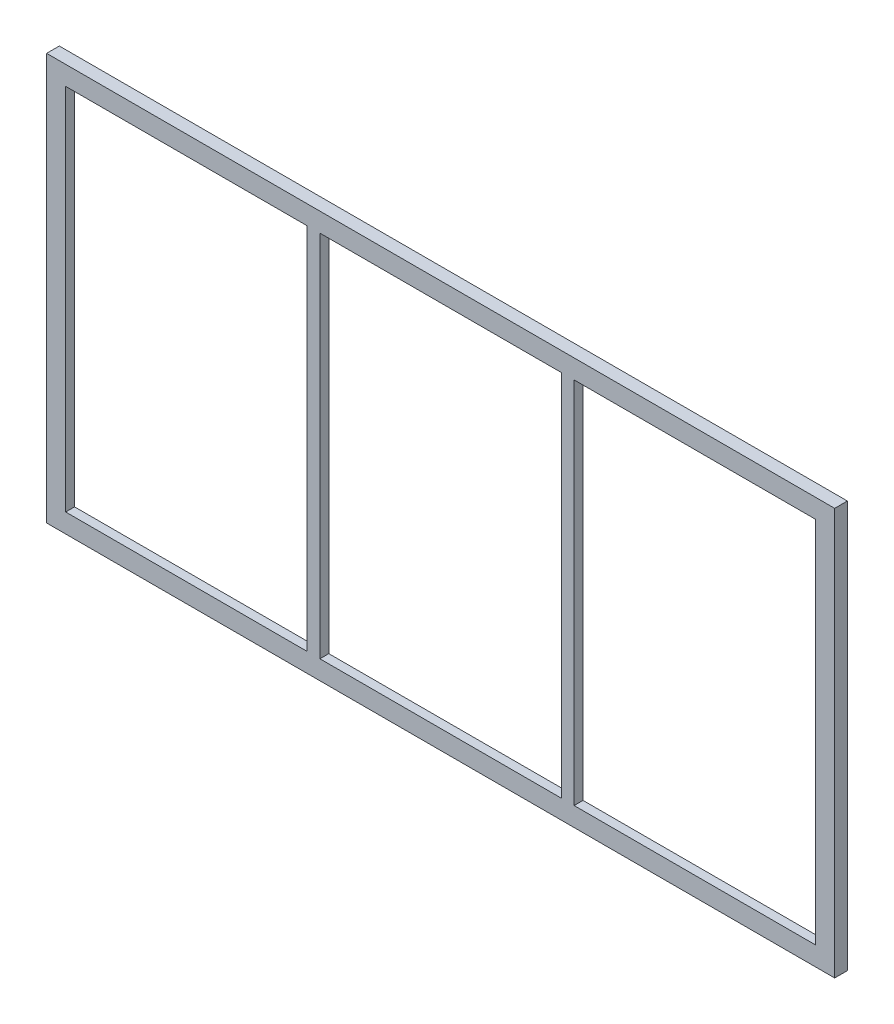
from build123d import *

# Parameters (mm, degrees)
CROQUIS1_W              = 620
CROQUIS1_H              = 320
CROQUIS1_W_2            = 190
CROQUIS1_H_2            = 290
SALIENTE_EXTRUIR1_DEPTH = 10
CROQUIS2_W              = 600
CROQUIS2_H              = 300
CORTAR_EXTRUIR1_DEPTH   = 3


with BuildPart() as part:
    # Croquis1 → Saliente-Extruir1 (new body)
    with BuildSketch(Plane.XY):
        with Locations((300, 150)):
            Rectangle(CROQUIS1_W, CROQUIS1_H)
        with Locations((100, 150)):
            Rectangle(CROQUIS1_W_2, CROQUIS1_H_2, mode=Mode.SUBTRACT)
        with Locations((500, 150)):
            Rectangle(CROQUIS1_W_2, CROQUIS1_H_2, mode=Mode.SUBTRACT)
        with Locations((300, 150)):
            Rectangle(CROQUIS1_W_2, CROQUIS1_H_2, mode=Mode.SUBTRACT)
    extrude(amount=SALIENTE_EXTRUIR1_DEPTH)

    # Croquis2 → Cortar-Extruir1 (cut)
    with BuildSketch(Plane(origin=(0, 0, 0), x_dir=(-1, 0, 0), z_dir=(0, 0, -1))):
        with Locations((-300, 150)):
            Rectangle(CROQUIS2_W, CROQUIS2_H)
    extrude(amount=-CORTAR_EXTRUIR1_DEPTH, mode=Mode.SUBTRACT)


solid = part.part
